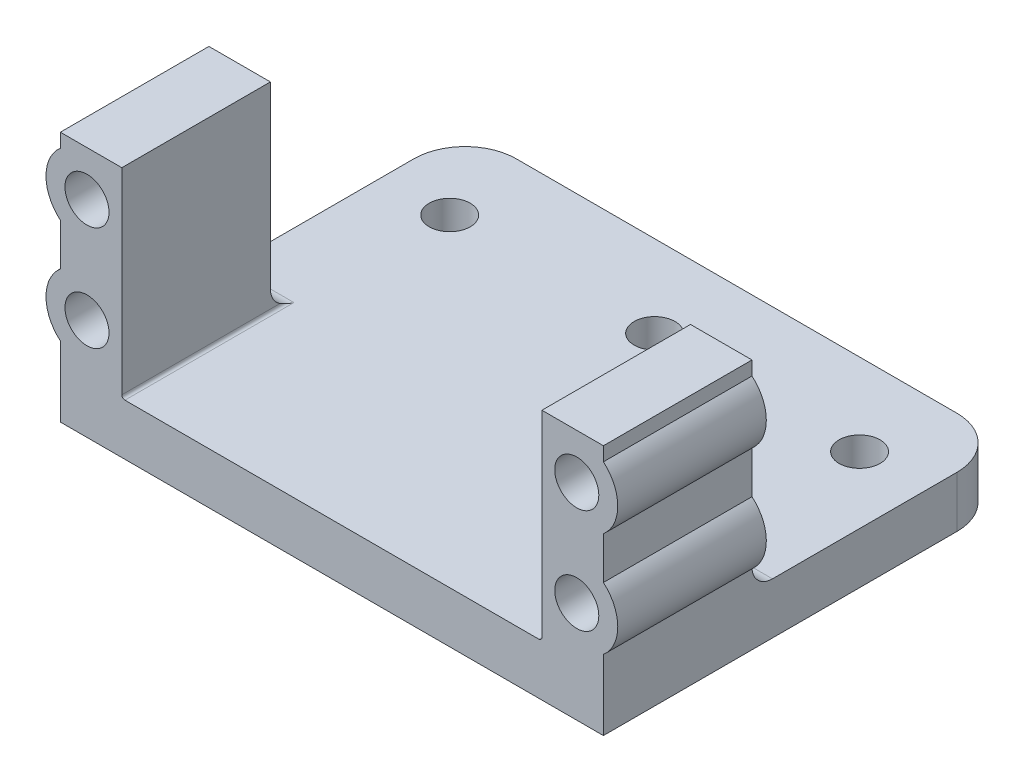
from build123d import *

# Parameters (mm, degrees)
BOSS_EXTRUDE1_DEPTH = 26.5
SKETCH4_W           = 6
SKETCH4_H           = 12
CUT_EXTRUDE2_DEPTH  = 19.5
FILLET2_R           = 0.3
FILLET3_R           = 0.3
BOSS_EXTRUDE3_DEPTH = 14.5
SKETCH8_R           = 2.15
CUT_EXTRUDE4_DEPTH  = 14.5
FILLET4_R           = 2
SKETCH9_W           = 53
SKETCH9_H           = 5
BOSS_EXTRUDE4_DEPTH = 13
SKETCH10_R          = 2
CUT_EXTRUDE5_DEPTH  = 10
FILLET9_R           = 5
SKETCH11_W          = 53
SKETCH11_H          = 5
BOSS_EXTRUDE5_DEPTH = 6.5
FILLET11_R          = 5
SKETCH12_W          = 57.342975089
SKETCH12_H          = 7.176836001
CUT_EXTRUDE6_DEPTH  = 5


with BuildPart() as part:
    # Sketch1 → Boss-Extrude1 (new body)
    with BuildSketch(Plane.XY):
        Polygon((-20.5, 2.5), (20.5, 2.5), (20.5, 22), (26.5, 22), (26.5, -2.5), (-26.5, -2.5), (-26.5, 22), (-20.5, 22), align=None)
    extrude(amount=BOSS_EXTRUDE1_DEPTH)

    # Sketch4 → Cut-Extrude2 (cut)
    with BuildSketch(Plane(origin=(0, 22, 0), x_dir=(1, 0, 0), z_dir=(0, 1, 0))):
        with Locations((-23.5, -6)):
            Rectangle(SKETCH4_W, SKETCH4_H)
        with Locations((23.5, -6)):
            Rectangle(SKETCH4_W, SKETCH4_H)
    extrude(amount=-CUT_EXTRUDE2_DEPTH, mode=Mode.SUBTRACT)

    # Fillet2
    fillet2_edges = [part.edges().sort_by_distance(p)[0] for p in [
        (20.5, 2.5, 19.25),
    ]]
    fillet(fillet2_edges, radius=FILLET2_R)

    # Fillet3
    fillet3_edges = [part.edges().sort_by_distance(p)[0] for p in [
        (-20.5, 2.5, 19.25),
    ]]
    fillet(fillet3_edges, radius=FILLET3_R)

    # Sketch7 → Boss-Extrude3 (add)
    with BuildSketch(Plane.XY.offset(26.5)):
        with BuildLine():
            Line((20.5, 19.707130751), (20.5, 15.492869249))
            ThreePointArc((20.5, 15.492869249), (27.9, 17.6), (20.5, 19.707130751))
        make_face()
        with BuildLine():
            Line((20.5, 9.507130751), (20.5, 5.292869249))
            ThreePointArc((20.5, 5.292869249), (27.9, 7.4), (20.5, 9.507130751))
        make_face()
    boss_extrude3 = extrude(amount=-BOSS_EXTRUDE3_DEPTH)

    # Sketch8 → Cut-Extrude4 (cut)
    with BuildSketch(Plane.XY.offset(26.5)):
        with Locations((23.9, 17.6)):
            Circle(SKETCH8_R)
        with Locations((23.9, 7.4)):
            Circle(SKETCH8_R)
    cut_extrude4 = extrude(amount=-CUT_EXTRUDE4_DEPTH, mode=Mode.SUBTRACT)

    # Mirror3: Boss-Extrude3, Cut-Extrude4 across plane
    add(boss_extrude3.mirror(Plane.ZY))
    add(cut_extrude4.mirror(Plane.ZY), mode=Mode.SUBTRACT)

    # Fillet4
    fillet4_edges = [part.edges().sort_by_distance(p)[0] for p in [
        (-23.35, 2.5, 12),
        (23.35, 2.5, 12),
    ]]
    fillet(fillet4_edges, radius=FILLET4_R)

    # Sketch9 → Boss-Extrude4 (add)
    with BuildSketch(Plane(origin=(0, 0, 0), x_dir=(-1, 0, 0), z_dir=(0, 0, -1))):
        Rectangle(SKETCH9_W, SKETCH9_H)
    extrude(amount=BOSS_EXTRUDE4_DEPTH)

    # Sketch10 → Cut-Extrude5 (cut)
    with BuildSketch(Plane(origin=(0, 2.5, 0), x_dir=(1, 0, 0), z_dir=(0, 1, 0))):
        with Locations((20, 5)):
            Circle(SKETCH10_R)
        with Locations((0, 5)):
            Circle(SKETCH10_R)
        with Locations((-20, 5)):
            Circle(SKETCH10_R)
    extrude(amount=-CUT_EXTRUDE5_DEPTH, mode=Mode.SUBTRACT)

    # Fillet9
    fillet9_edges = [part.edges().sort_by_distance(p)[0] for p in [
        (-26.5, 0, -13),
        (26.5, 0, -13),
    ]]
    fillet(fillet9_edges, radius=FILLET9_R)

    # Sketch11 → Boss-Extrude5 (add)
    with BuildSketch(Plane.XY.offset(26.5)):
        Rectangle(SKETCH11_W, SKETCH11_H)
    extrude(amount=BOSS_EXTRUDE5_DEPTH)

    # Fillet11
    fillet11_edges = [part.edges().sort_by_distance(p)[0] for p in [
        (-26.5, 0, 33),
        (26.5, 0, 33),
    ]]
    fillet(fillet11_edges, radius=FILLET11_R)

    # Sketch12 → Cut-Extrude6 (cut)
    with BuildSketch(Plane(origin=(0, 2.5, 0), x_dir=(1, 0, 0), z_dir=(0, 1, 0))):
        with Locations((-0.596167356, -30.088418001)):
            Rectangle(SKETCH12_W, SKETCH12_H)
    extrude(amount=-CUT_EXTRUDE6_DEPTH, mode=Mode.SUBTRACT)


solid = part.part
